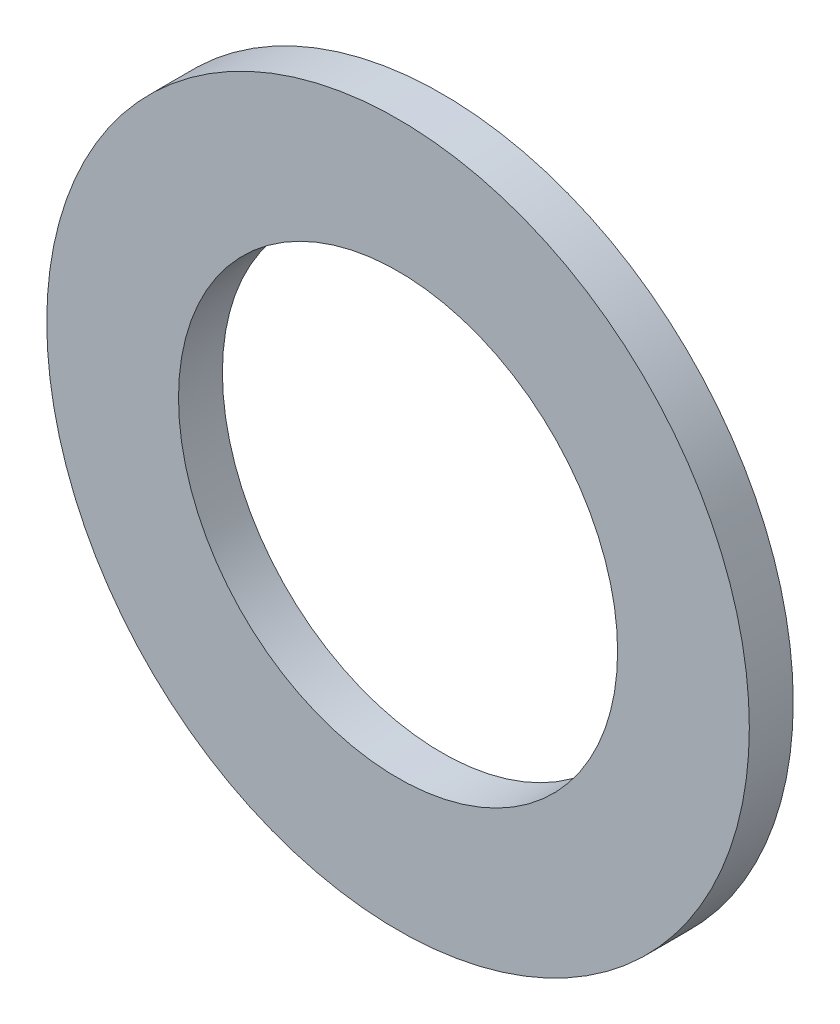
from build123d import *

# Parameters (mm, degrees)
SKETCH1_R           = 8
SKETCH1_R_2         = 5
BOSS_EXTRUDE1_DEPTH = 1


with BuildPart() as part:
    # Sketch1 → Boss-Extrude1 (new body)
    with BuildSketch(Plane.XY):
        Circle(SKETCH1_R)
        Circle(SKETCH1_R_2, mode=Mode.SUBTRACT)
    extrude(amount=BOSS_EXTRUDE1_DEPTH)


solid = part.part
